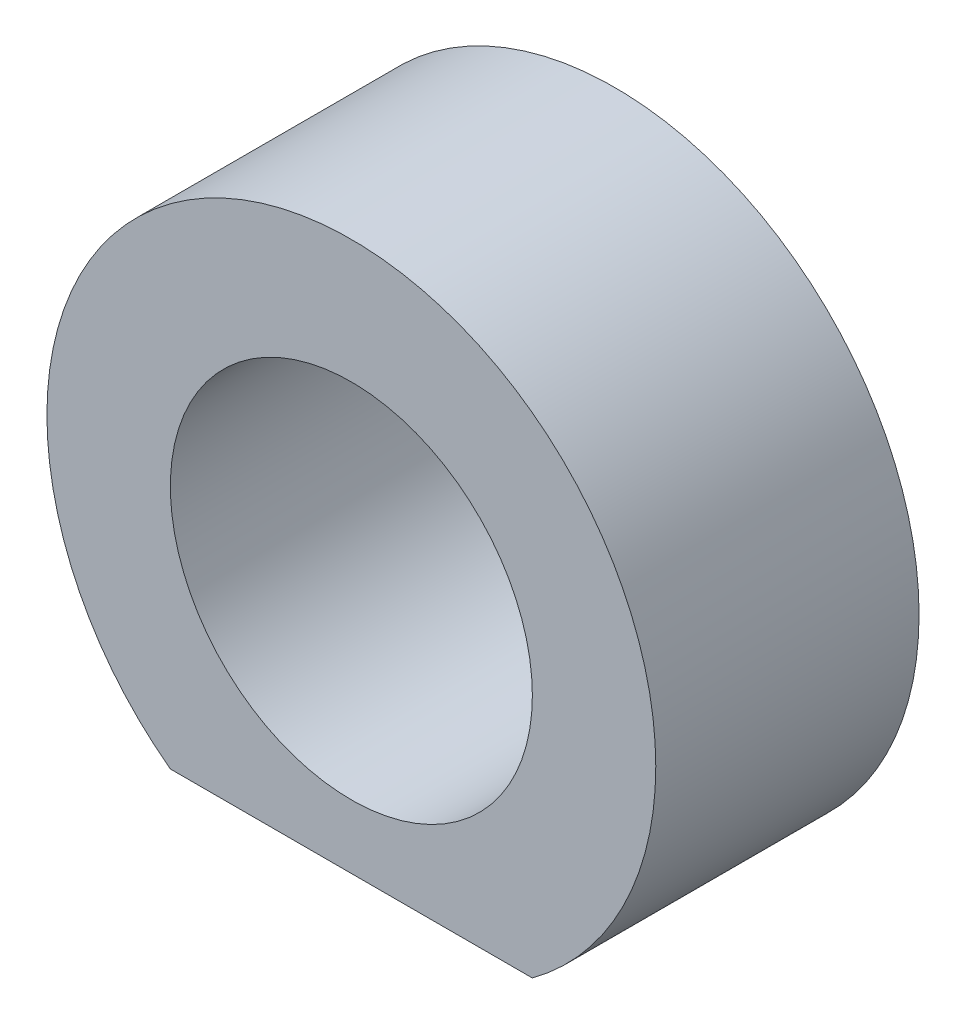
from build123d import *

# Parameters (mm, degrees)
SKETCH1_R           = 18.5
SKETCH1_R_2         = 11
BOSS_EXTRUDE1_DEPTH = 8
CUT_EXTRUDE1_DEPTH  = 16
SKETCH4_R           = 1
CUT_EXTRUDE2_DEPTH  = 2
CHAMFER1_SIZE       = 0.3


with BuildPart() as part:
    # Sketch1 → Boss-Extrude1 (new body, symmetric)
    with BuildSketch(Plane.XY):
        Circle(SKETCH1_R)
        Circle(SKETCH1_R_2, mode=Mode.SUBTRACT)
    extrude(amount=BOSS_EXTRUDE1_DEPTH, both=True)

    # Sketch3 → Cut-Extrude1 (cut)
    with BuildSketch(Plane(origin=(0, 0, -8), x_dir=(-1, 0, 0), z_dir=(0, 0, -1))):
        with BuildLine():
            Line((-11, -14.874474781), (11, -14.874474781))
            ThreePointArc((11, -14.874474781), (0, -18.5), (-11, -14.874474781))
        make_face()
    extrude(amount=-CUT_EXTRUDE1_DEPTH, mode=Mode.SUBTRACT)

    # Sketch4 → Cut-Extrude2 (cut)
    with BuildSketch(Plane.XZ.offset(14.874474781)):
        Circle(SKETCH4_R)
    extrude(amount=-CUT_EXTRUDE2_DEPTH, mode=Mode.SUBTRACT)

    # Chamfer1
    chamfer1_edges = [part.edges().sort_by_distance(p)[0] for p in [
        (-1, -12.874474781, 0),
    ]]
    chamfer(chamfer1_edges, length=CHAMFER1_SIZE)


solid = part.part
